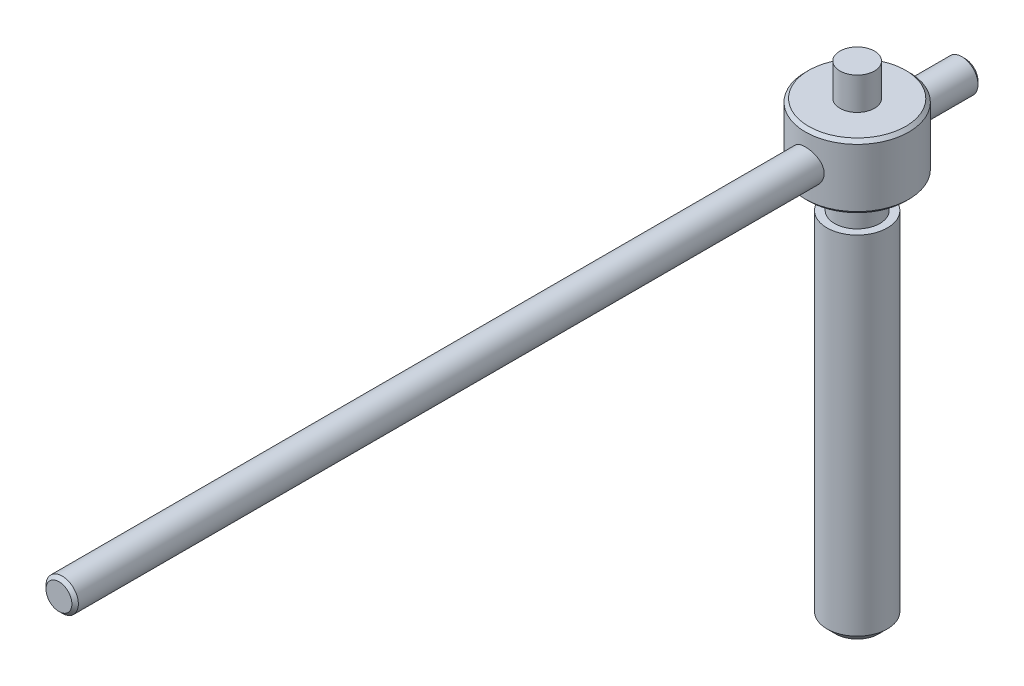
from build123d import *

# Parameters (mm, degrees)
SKETCH_1_R           = 14
EXTRUDE_1_DEPTH      = 165
SKETCH_2_R           = 10.5
EXTRUDE_2_DEPTH      = 15
CHAMFER_2_SIZE       = 4
SKETCH_4_R           = 24
EXTRUDE_3_DEPTH      = 30
SKETCH_5_R           = 8
EXTRUDE_4_DEPTH      = 15
SKETCH_6_R           = 7.5
EXTRUDE_5_DEPTH      = 370
EXTRUDE_5_DEPTH_BACK = 50
CHAMFER_3_SIZE       = 1.5


with BuildPart() as part:
    # 草图1 → 凸台-拉伸1 (new body)
    with BuildSketch(Plane(origin=(0, 0, 0), x_dir=(1, 0, 0), z_dir=(0, 1, 0))):
        Circle(SKETCH_1_R)
    extrude(amount=EXTRUDE_1_DEPTH)

    # 草图2 → 凸台-拉伸2 (add)
    with BuildSketch(Plane(origin=(0, 165, 0), x_dir=(1, 0, 0), z_dir=(0, 1, 0))):
        Circle(SKETCH_2_R)
    extrude(amount=EXTRUDE_2_DEPTH)

    # 倒角2
    chamfer_2_edges = [part.edges().sort_by_distance(p)[0] for p in [
        (-14, 0, 0),
    ]]
    chamfer(chamfer_2_edges, length=CHAMFER_2_SIZE)

    # 草图4 → 凸台-拉伸3 (add)
    with BuildSketch(Plane(origin=(0, 180, 0), x_dir=(1, 0, 0), z_dir=(0, 1, 0))):
        Circle(SKETCH_4_R)
    extrude(amount=EXTRUDE_3_DEPTH)

    # 草图5 → 凸台-拉伸4 (add)
    with BuildSketch(Plane(origin=(0, 210, 0), x_dir=(1, 0, 0), z_dir=(0, 1, 0))):
        Circle(SKETCH_5_R)
    extrude(amount=EXTRUDE_4_DEPTH)

    # 草图6 → 凸台-拉伸5 (add, two sides)
    with BuildSketch(Plane.XY) as extrude_5_sk:
        with Locations((0, 195)):
            Circle(SKETCH_6_R)
    extrude(amount=EXTRUDE_5_DEPTH)
    extrude(extrude_5_sk.sketch, amount=-EXTRUDE_5_DEPTH_BACK)

    # 倒角3
    chamfer_3_edges = [part.edges().sort_by_distance(p)[0] for p in [
        (-24, 180, 0),
        (-24, 210, 0),
        (-7.5, 195, -50),
        (-7.5, 195, 370),
    ]]
    chamfer(chamfer_3_edges, length=CHAMFER_3_SIZE)


solid = part.part
